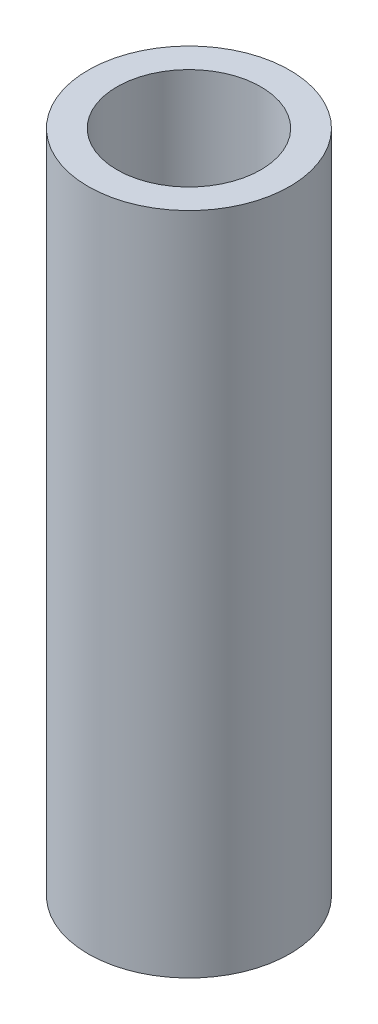
from build123d import *

# Parameters (mm, degrees)
SKETCH1_R           = 4.572
SKETCH1_R_2         = 3.2639
BOSS_EXTRUDE1_DEPTH = 30.1498


with BuildPart() as part:
    # Sketch1 → Boss-Extrude1 (new body)
    with BuildSketch(Plane(origin=(0, 0, 0), x_dir=(1, 0, 0), z_dir=(0, 1, 0))):
        Circle(SKETCH1_R)
        Circle(SKETCH1_R_2, mode=Mode.SUBTRACT)
    extrude(amount=BOSS_EXTRUDE1_DEPTH)


solid = part.part
